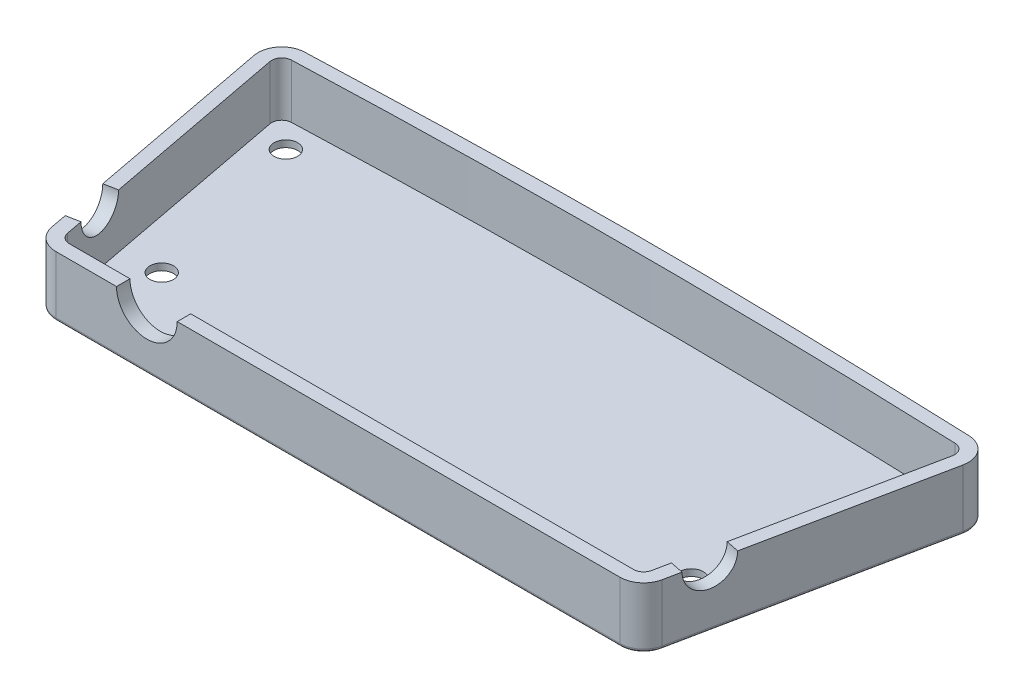
from build123d import *

# Parameters (mm, degrees)
SKETCH1_R           = 1.75
BOSS_EXTRUDE1_DEPTH = 1
BOSS_EXTRUDE2_DEPTH = 9
CUT_EXTRUDE2_DEPTH  = 2
CUT_EXTRUDE3_DEPTH  = 7
FILLET1_R           = 0.5
CUT_EXTRUDE4_DEPTH  = 2


with BuildPart() as part:
    # Sketch1 → Boss-Extrude1 (new body)
    with BuildSketch(Plane(origin=(0, 0, 0), x_dir=(1, 0, 0), z_dir=(0, 1, 0))):
        with BuildLine():
            ThreePointArc((-3.131484069, 5.892071798), (-5.737365292, 4.575348005), (-6.438282309, 1.7410767))
            Line((-6.438282309, 1.7410767), (0.60003894, -35.29332564))
            ThreePointArc((0.60003894, -35.29332564), (1.806583814, -37.335883181), (4.03849413, -38.139853444))
            Line((4.03849413, -38.139853444), (87.670939293, -38.139853444))
            ThreePointArc((87.670939293, -38.139853444), (89.884160785, -37.35124619), (91.100032265, -35.340796659))
            Line((91.100032265, -35.340796659), (98.669943789, 1.692061139))
            ThreePointArc((98.669943789, 1.692061139), (97.993413035, 4.554809441), (95.372557333, 5.890525389))
            add(Edge.make_bspline(
                [(-3.131484069, 5.892071798), (46.109282616, 7.745637681), (95.372557333, 5.890525389)],
                knots=[0.096020277, 0.096020277, 0.096020277, 0.904206285, 0.904206285, 0.904206285], degree=2, weights=[1.148800657, 1.708499103, 1.148486764]))
        make_face()
        with Locations((6.60003894, -24.999988489)):
            Circle(SKETCH1_R, mode=Mode.SUBTRACT)
        with Locations((85.100032265, -24.999862922)):
            Circle(SKETCH1_R, mode=Mode.SUBTRACT)
        Circle(SKETCH1_R, mode=Mode.SUBTRACT)
        with Locations((92.2, 0)):
            Circle(SKETCH1_R, mode=Mode.SUBTRACT)
    extrude(amount=BOSS_EXTRUDE1_DEPTH)

    # Sketch1_5 → Boss-Extrude2 (add)
    with BuildSketch(Plane(origin=(0, 0, 0), x_dir=(1, 0, 0), z_dir=(0, 1, 0))):
        with BuildLine():
            ThreePointArc((-3.131484069, 5.892071798), (-5.737365292, 4.575348005), (-6.438282309, 1.7410767))
            Line((-6.438282309, 1.7410767), (0.60003894, -35.29332564))
            ThreePointArc((0.60003894, -35.29332564), (1.806583814, -37.335883181), (4.03849413, -38.139853444))
            Line((4.03849413, -38.139853444), (87.670939293, -38.139853444))
            ThreePointArc((87.670939293, -38.139853444), (89.884160785, -37.35124619), (91.100032265, -35.340796659))
            Line((91.100032265, -35.340796659), (98.669943789, 1.692061139))
            ThreePointArc((98.669943789, 1.692061139), (97.993413035, 4.554809441), (95.372557333, 5.890525389))
            add(Edge.make_bspline(
                [(-3.131484069, 5.892071798), (46.109282616, 7.745637681), (95.372557333, 5.890525389)],
                knots=[0.096020277, 0.096020277, 0.096020277, 0.904206285, 0.904206285, 0.904206285], degree=2, weights=[1.148800657, 1.708499103, 1.148486764]))
        make_face()
        with BuildLine():
            ThreePointArc((95.297296467, 3.89194194), (96.420520339, 3.319492248), (96.710462091, 2.092600119))
            Line((96.710462091, 2.092600119), (89.140550566, -34.940257679))
            ThreePointArc((89.140550566, -34.940257679), (88.619462789, -35.801878907), (87.670939293, -36.139853444))
            Line((87.670939293, -36.139853444), (4.03849413, -36.139853444))
            ThreePointArc((4.03849413, -36.139853444), (3.081961137, -35.79529476), (2.564870477, -34.919912956))
            Line((2.564870477, -34.919912956), (-4.473450772, 2.114489384))
            ThreePointArc((-4.473450772, 2.114489384), (-4.173057765, 3.329177086), (-3.056251526, 3.893487283))
            ThreePointArc((-3.056251526, 3.893487283), (46.120537007, 4.817927579), (95.297296467, 3.89194194))
        make_face(mode=Mode.SUBTRACT)
    extrude(amount=BOSS_EXTRUDE2_DEPTH)

    # Sketch2 → Cut-Extrude2 (cut)
    with BuildSketch(Plane(origin=(94.380499607, 0, 19.292381797), x_dir=(0.20026949000025768, 0, -0.9797408490897156), z_dir=(0.9797408490897156, 0, 0.20026949000025768))):
        with BuildLine():
            Line((-6.880265125, 9), (-13.880265125, 9))
            ThreePointArc((-13.880265125, 9), (-10.380265125, 5.5), (-6.880265125, 9))
        make_face()
    extrude(amount=-CUT_EXTRUDE2_DEPTH, mode=Mode.SUBTRACT)

    # Sketch3 → Cut-Extrude3 (cut)
    with BuildSketch(Plane.XY.offset(38.139853444)):
        with BuildLine():
            Line((22.03849413, 9), (13.03849413, 9))
            ThreePointArc((13.03849413, 9), (17.53849413, 4.5), (22.03849413, 9))
        make_face()
    extrude(amount=-CUT_EXTRUDE3_DEPTH, mode=Mode.SUBTRACT)

    # Fillet1
    fillet1_edges = [part.edges().sort_by_distance(p)[0] for p in [
        (45.854716711, 0, 38.139853444),
        (89.884160785, 0, 37.35124619),
        (94.884988027, 0, 16.82436776),
        (97.993413035, 0, -4.554809441),
        (46.120186786, 0, -7.000146325),
        (-5.737365292, 0, -4.575348005),
        (-2.919121684, 0, 16.77612447),
        (1.806583814, 0, 37.335883181),
    ]]
    fillet(fillet1_edges, radius=FILLET1_R)

    # Sketch4 → Cut-Extrude4 (cut)
    with BuildSketch(Plane(origin=(-5.89449461, 0, 1.12023805), x_dir=(0.1867063417029029, 0, 0.9824157683831826), z_dir=(-0.9824157683831826, 0, 0.1867063417029029))):
        with BuildLine():
            Line((25.284750703, 9), (32.284750703, 9))
            ThreePointArc((32.284750703, 9), (28.784750703, 5.5), (25.284750703, 9))
        make_face()
    extrude(amount=-CUT_EXTRUDE4_DEPTH, mode=Mode.SUBTRACT)


solid = part.part
